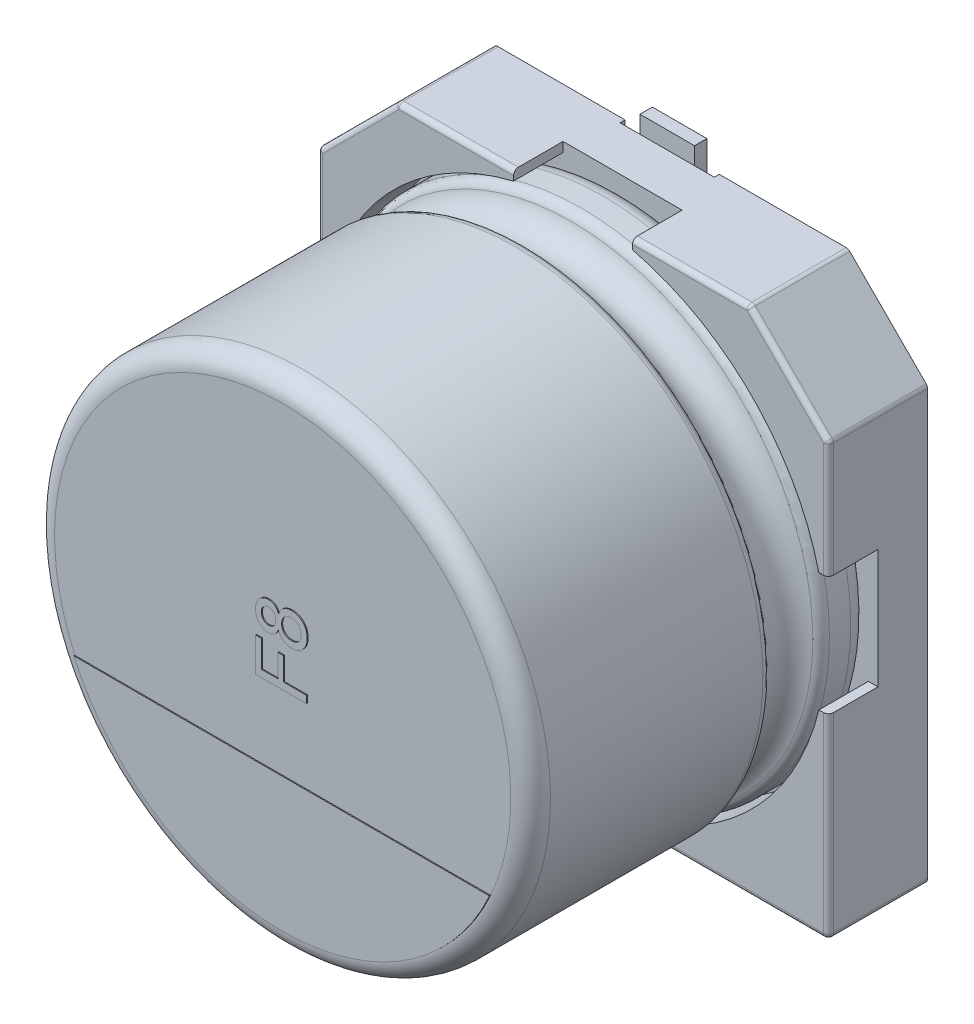
from build123d import *

# Parameters (mm, degrees)
BOSS_EXTRUDE1_DEPTH  = 1
BOSS_EXTRUDE2_DEPTH  = 1
SKETCH7_R            = 0.35
SPACER_PAD_DEPTH     = 0.15
SKETCH9_W            = 1.9
SKETCH9_H            = 3.05
CUT_EXTRUDE1_DEPTH   = 0.1
FILLET1_R            = 0.1
FILLET2_R            = 0.1
CATHODE_MARKER_DEPTH = 0.02
TEXT_2_DEPTH         = 0.02
SKETCH19_W           = 1.1
SKETCH19_H           = 3.2
BOSS_EXTRUDE6_DEPTH  = 0.25


with BuildPart() as part:
    # Sketch2 → Boss-Extrude1 (new body)
    with BuildSketch(Plane.XY):
        Polygon((-5.15, 3.55), (-3.55, 5.15), (3.55, 5.15), (5.15, 3.55), (5.15, -5.15), (-5.15, -5.15), align=None)
    extrude(amount=BOSS_EXTRUDE1_DEPTH)

    # Sketch4 → Boss-Extrude2 (add)
    with BuildSketch(Plane.XY.offset(1)):
        with BuildLine():
            Line((-5.15, 3.55), (-3.55, 5.15))
            Line((-3.55, 5.15), (-1.2, 5.15))
            Line((-1.2, 5.15), (-1.2, 4.956813493))
            ThreePointArc((-1.2, 4.956813493), (-3.606244584, 3.606244584), (-4.956813493, 1.2))
            Line((-4.956813493, 1.2), (-5.15, 1.2))
            Line((-5.15, 1.2), (-5.15, 3.55))
        make_face()
        with BuildLine():
            Line((3.55, 5.15), (5.15, 3.55))
            Line((5.15, 3.55), (5.15, 1.2))
            Line((5.15, 1.2), (4.956813493, 1.2))
            ThreePointArc((4.956813493, 1.2), (3.606244584, 3.606244584), (1.2, 4.956813493))
            Line((1.2, 4.956813493), (1.2, 5.15))
            Line((1.2, 5.15), (3.55, 5.15))
        make_face()
        with BuildLine():
            Line((5.15, -1.2), (5.15, -5.15))
            Line((5.15, -5.15), (1.2, -5.15))
            Line((1.2, -5.15), (1.2, -4.956813493))
            ThreePointArc((1.2, -4.956813493), (3.606244584, -3.606244584), (4.956813493, -1.2))
            Line((4.956813493, -1.2), (5.15, -1.2))
        make_face()
        with BuildLine():
            Line((-5.15, -1.2), (-5.15, -5.15))
            Line((-5.15, -5.15), (-1.2, -5.15))
            Line((-1.2, -5.15), (-1.2, -4.956813493))
            ThreePointArc((-1.2, -4.956813493), (-3.606244584, -3.606244584), (-4.956813493, -1.2))
            Line((-4.956813493, -1.2), (-5.15, -1.2))
        make_face()
    extrude(amount=BOSS_EXTRUDE2_DEPTH)

    # Sketch7 → Spacer Pad (add)
    with BuildSketch(Plane(origin=(0, 0, 0), x_dir=(1, 0, 0), z_dir=(0, 0, -1))):
        with Locations((-3.581612435, 3.54735769)):
            Circle(SKETCH7_R)
        with Locations((3.581612435, 3.54735769)):
            Circle(SKETCH7_R)
        with Locations((-3.581612435, -3.54735769)):
            Circle(SKETCH7_R)
        with Locations((3.581612435, -3.54735769)):
            Circle(SKETCH7_R)
    extrude(amount=SPACER_PAD_DEPTH)

    # Sketch9 → Cut-Extrude1 (cut)
    with BuildSketch(Plane(origin=(0, 0, 0), x_dir=(1, 0, 0), z_dir=(0, 0, -1))):
        with Locations((0, 3.625)):
            Rectangle(SKETCH9_W, SKETCH9_H)
        with Locations((0, -3.625)):
            Rectangle(SKETCH9_W, SKETCH9_H)
    extrude(amount=-CUT_EXTRUDE1_DEPTH, mode=Mode.SUBTRACT)

    # Fillet1
    fillet1_edges = [part.edges().sort_by_distance(p)[0] for p in [
        (5.15, -5.15, 1),
        (-5.15, -5.15, 1),
        (-5.15, 3.55, 1),
        (-3.55, 5.15, 1),
        (3.55, 5.15, 1),
        (5.15, 3.55, 1),
    ]]
    fillet(fillet1_edges, radius=FILLET1_R)

    # Sketch10 → Revolve1 (revolve)
    with BuildSketch(Plane(origin=(0, 0, 0), x_dir=(0, 0, -1), z_dir=(1, 0, 0))):
        with BuildLine():
            Line((-7.853626625, 0), (-1, 0))
            Line((-1, 0), (-1, 4.6))
            ThreePointArc((-1, 4.6), (-1.117157288, 4.882842712), (-1.4, 5))
            Line((-1.4, 5), (-1.829179607, 5))
            ThreePointArc((-1.829179607, 5), (-1.948702468, 4.960356745), (-2.020842576, 4.857142857))
            ThreePointArc((-2.020842576, 4.857142857), (-2.5, 4.5), (-2.979157424, 4.857142857))
            ThreePointArc((-2.979157424, 4.857142857), (-3.051297532, 4.960356745), (-3.170820393, 5))
            Line((-3.170820393, 5), (-7.453626625, 5))
            ThreePointArc((-7.453626625, 5), (-7.736469337, 4.882842712), (-7.853626625, 4.6))
            Line((-7.853626625, 4.6), (-7.853626625, 0))
        make_face()
    revolve(axis=Axis((0, 0, -18.9630778), (0, 0, 1)))

    # Fillet2
    fillet2_edges = [part.edges().sort_by_distance(p)[0] for p in [
        (3.125, -5.15, 2),
        (5.120710678, -5.120710678, 2),
        (5.15, 2.354289322, 2),
        (5.142387953, 3.546846987, 2),
        (2.354289322, 5.15, 2),
        (3.546846987, 5.142387953, 2),
        (-2.354289322, 5.15, 2),
        (-3.546846987, 5.142387953, 2),
        (-4.35, 4.35, 2),
        (-5.142387953, 3.546846987, 2),
        (-5.15, -3.125, 2),
        (-5.120710678, -5.120710678, 2),
        (5.15, -3.125, 2),
        (4.35, 4.35, 2),
        (-5.15, 2.354289322, 2),
        (-3.125, -5.15, 2),
    ]]
    fillet(fillet2_edges, radius=FILLET2_R)

    # Sketch13 → Cathode marker (add)
    with BuildSketch(Plane.XY.offset(7.853626625)):
        with BuildLine():
            Line((-4.192254052, -1.893411197), (4.192254052, -1.893411197))
            ThreePointArc((4.192254052, -1.893411197), (0, -4.6), (-4.192254052, -1.893411197))
        make_face()
    extrude(amount=CATHODE_MARKER_DEPTH)

    # Sketch15 → Text 2 (add)
    with BuildSketch(Plane.XY.offset(7.853626625)):
        Polygon((0.5, -0.381462215), (-0.527327474, -0.381462215), (-0.527327474, 0.303422768), (-0.408789689, 0.303422768), (-0.408789689, -0.236582699), (-0.079518062, -0.236582699), (-0.079518062, 0.224397578), (0.039019723, 0.224397578), (0.039019723, -0.236582699), (0.5, -0.236582699), align=None)
        with BuildLine():
            add(Edge.make_bspline(
                [(-0.06346607, 0.630224857), (-0.068354899, 0.617728032), (-0.077728405, 0.593767474), (-0.096487429, 0.561450859), (-0.118067216, 0.534100009), (-0.142988147, 0.512050759), (-0.17073504, 0.495245221), (-0.200954123, 0.483144569), (-0.233813748, 0.476057005), (-0.256535333, 0.4751242), (-0.268231863, 0.474644014)],
                knots=[0, 0, 0, 0, 1.16287356, 2.229614231, 3.228817875, 4.173350329, 5.100165549, 6.029633206, 6.985702163, 8, 8, 8, 8], degree=3))
            add(Edge.make_bspline(
                [(-0.268231863, 0.474644014), (-0.277232165, 0.474869153), (-0.29490004, 0.475311109), (-0.320818877, 0.479156569), (-0.345615231, 0.485235553), (-0.369240102, 0.494102611), (-0.392048008, 0.504848512), (-0.413437716, 0.518699867), (-0.434030491, 0.534521), (-0.453013793, 0.553071964), (-0.470402473, 0.573510242), (-0.485876208, 0.595649315), (-0.498530082, 0.619657127), (-0.509109754, 0.645133792), (-0.517392528, 0.672205173), (-0.523033555, 0.700966658), (-0.526621668, 0.73131685), (-0.527088541, 0.752113523), (-0.527327474, 0.762756687)],
                knots=[0, 0, 0, 0, 0.994120188, 1.951489002, 2.889176796, 3.810168517, 4.735797202, 5.669554404, 6.620327554, 7.601413351, 8.596342518, 9.582569514, 10.579662357, 11.589070759, 12.627413041, 13.702304436, 14.824102725, 16, 16, 16, 16], degree=3))
            add(Edge.make_bspline(
                [(-0.527327474, 0.762756687), (-0.527086115, 0.77346767), (-0.526615976, 0.794331457), (-0.523076073, 0.824842893), (-0.517142977, 0.853785883), (-0.508725404, 0.881143376), (-0.497963042, 0.906958535), (-0.484734644, 0.931061617), (-0.469258577, 0.953701153), (-0.451349578, 0.974296996), (-0.431908305, 0.993041001), (-0.411072648, 1.00926575), (-0.389310753, 1.023268876), (-0.366468595, 1.034605267), (-0.342477715, 1.043273729), (-0.317627507, 1.049701953), (-0.291602408, 1.053478006), (-0.27393779, 1.053931208), (-0.264939147, 1.054162076)],
                knots=[0, 0, 0, 0, 1.17123639, 2.281436327, 3.354066579, 4.398218719, 5.40700272, 6.407523026, 7.400164541, 8.400262835, 9.387217769, 10.349220476, 11.2836808, 12.213067748, 13.131580738, 14.068687581, 15.016158091, 16, 16, 16, 16], degree=3))
            add(Edge.make_bspline(
                [(-0.264939147, 1.054162076), (-0.253645841, 1.053785591), (-0.231501792, 1.053047375), (-0.199579354, 1.045527123), (-0.169784312, 1.033800759), (-0.142655025, 1.016872367), (-0.117991462, 0.995331285), (-0.096234769, 0.968911116), (-0.077820532, 0.937308758), (-0.068384192, 0.914014612), (-0.06346607, 0.901873949)],
                knots=[0, 0, 0, 0, 0.998585552, 1.958038425, 2.887636572, 3.823348935, 4.774921793, 5.776035998, 6.840893412, 8, 8, 8, 8], degree=3))
            add(Edge.make_bspline(
                [(-0.06346607, 0.901873949), (-0.060862641, 0.909543442), (-0.055761048, 0.924572322), (-0.04584198, 0.945818674), (-0.035146871, 0.965821476), (-0.023569407, 0.984693522), (-0.010248607, 1.001738218), (0.00402795, 1.017524151), (0.019461358, 1.031985221), (0.036183215, 1.044922897), (0.053841314, 1.05647651), (0.072483356, 1.066356607), (0.091886088, 1.074813533), (0.112087026, 1.081859998), (0.133157783, 1.087220063), (0.15505702, 1.090842682), (0.177743724, 1.093179531), (0.193154177, 1.093507908), (0.200980204, 1.093674671)],
                knots=[0, 0, 0, 0, 1.104224237, 2.163800432, 3.193825792, 4.198757877, 5.179651902, 6.140335883, 7.100472673, 8.060837497, 9.021293519, 9.975895278, 10.935667101, 11.906463585, 12.891589942, 13.897828549, 14.932435592, 16, 16, 16, 16], degree=3))
            add(Edge.make_bspline(
                [(0.200980204, 1.093674671), (0.211766209, 1.093412666), (0.233015459, 1.092896496), (0.26420908, 1.088369563), (0.294166278, 1.081500633), (0.322741766, 1.071575782), (0.349926401, 1.058632915), (0.375922546, 1.043019303), (0.400458109, 1.024360181), (0.423424312, 1.003168612), (0.444607119, 0.979931258), (0.463042568, 0.954460148), (0.478495248, 0.927073343), (0.491395014, 0.89804463), (0.50090607, 0.867031977), (0.508283383, 0.834461777), (0.512303421, 0.799968902), (0.512877843, 0.77641717), (0.513170865, 0.764403045)],
                knots=[0, 0, 0, 0, 1.017684271, 2.004915574, 2.969350057, 3.91550174, 4.854021697, 5.806886265, 6.773058391, 7.758397691, 8.753308551, 9.736453685, 10.719577492, 11.717014045, 12.728747378, 13.776699948, 14.865858151, 16, 16, 16, 16], degree=3))
            add(Edge.make_bspline(
                [(0.513170865, 0.764403045), (0.512880184, 0.752388096), (0.51231035, 0.728834748), (0.508257359, 0.694353476), (0.500993774, 0.661721267), (0.49106014, 0.630864182), (0.478602189, 0.601614834), (0.462789127, 0.574405171), (0.444350128, 0.548860334), (0.423269613, 0.525384311), (0.40009517, 0.504226358), (0.375232143, 0.485808918), (0.349063166, 0.470109933), (0.321440718, 0.45719001), (0.292364548, 0.447342081), (0.261943817, 0.440430689), (0.230201772, 0.435891796), (0.208542071, 0.435388449), (0.197481693, 0.435131419)],
                knots=[0, 0, 0, 0, 1.127066097, 2.209429196, 3.250843736, 4.258219581, 5.246860502, 6.227045772, 7.204057202, 8.19754525, 9.181483529, 10.142920909, 11.095356922, 12.039670968, 12.998174893, 13.969127444, 14.962948905, 16, 16, 16, 16], degree=3))
            add(Edge.make_bspline(
                [(0.197481693, 0.435131419), (0.189246409, 0.435310056), (0.173087356, 0.435660572), (0.149386601, 0.437802244), (0.126796614, 0.442069091), (0.105187415, 0.447569664), (0.084493636, 0.454537156), (0.064863806, 0.463216556), (0.046256659, 0.473537299), (0.028790272, 0.485492066), (0.012456006, 0.498840473), (-0.002360853, 0.513783706), (-0.01598593, 0.529886288), (-0.028435302, 0.547220798), (-0.039376701, 0.566040821), (-0.048734162, 0.586294961), (-0.057112711, 0.607690465), (-0.061327074, 0.622638166), (-0.06346607, 0.630224857)],
                knots=[0, 0, 0, 0, 1.117192714, 2.192125398, 3.223277125, 4.232061974, 5.214850236, 6.181337876, 7.139322725, 8.096810377, 9.04872078, 9.996164021, 10.946891304, 11.907403346, 12.887280159, 13.894604929, 14.93140868, 16, 16, 16, 16], degree=3))
        make_face()
        with BuildLine():
            add(Edge.make_bspline(
                [(-0.267614479, 0.606352664), (-0.257129573, 0.606743584), (-0.236868083, 0.607499015), (-0.208087697, 0.615714054), (-0.182236441, 0.628560707), (-0.163484759, 0.643618999), (-0.150719359, 0.658060881), (-0.142164759, 0.670101748), (-0.135012669, 0.683333668), (-0.128993841, 0.697571346), (-0.124418959, 0.712960773), (-0.121517723, 0.729542592), (-0.119286059, 0.747193981), (-0.119117208, 0.759387586), (-0.119030657, 0.765637813)],
                knots=[0, 0, 0, 0, 1.528611259, 2.9539551, 4.33488699, 5.725248612, 6.435430486, 7.147520411, 7.878829355, 8.629199951, 9.403175758, 10.219188982, 11.087187622, 12, 12, 12, 12], degree=3))
            add(Edge.make_bspline(
                [(-0.119030657, 0.765637813), (-0.119118527, 0.771750551), (-0.119289868, 0.783670055), (-0.121500048, 0.800917287), (-0.124496051, 0.817197129), (-0.1288828, 0.832380294), (-0.135118016, 0.846282108), (-0.14191772, 0.859386968), (-0.150526036, 0.871162403), (-0.163313755, 0.885282045), (-0.181426583, 0.900214979), (-0.205975026, 0.913234897), (-0.232964043, 0.92120307), (-0.251781791, 0.922029323), (-0.261440636, 0.922453425)],
                knots=[0, 0, 0, 0, 0.922426077, 1.79868034, 2.621444266, 3.421127716, 4.177365866, 4.918918382, 5.646226505, 6.372279565, 7.792748194, 9.164334355, 10.544498862, 12, 12, 12, 12], degree=3))
            add(Edge.make_bspline(
                [(-0.261440636, 0.922453425), (-0.271437729, 0.921944865), (-0.290999452, 0.920949743), (-0.319104756, 0.912959472), (-0.344515741, 0.899362045), (-0.363325638, 0.88420153), (-0.376567635, 0.869715951), (-0.385082022, 0.857520324), (-0.392715367, 0.844570951), (-0.398298846, 0.830316684), (-0.4031971, 0.815320156), (-0.406317846, 0.79921269), (-0.408535579, 0.782163313), (-0.408703203, 0.770447701), (-0.408789689, 0.764403045)],
                knots=[0, 0, 0, 0, 1.480375879, 2.896712224, 4.288636353, 5.727462819, 6.454578368, 7.191019914, 7.928864207, 8.676661479, 9.454949272, 10.264623217, 11.104634354, 12, 12, 12, 12], degree=3))
            add(Edge.make_bspline(
                [(-0.408789689, 0.764403045), (-0.408707781, 0.758357199), (-0.408548105, 0.746571118), (-0.406239515, 0.729417769), (-0.403494721, 0.713112148), (-0.398497735, 0.698074812), (-0.392892961, 0.683878498), (-0.385509663, 0.670876063), (-0.377188483, 0.658686443), (-0.364322549, 0.644327219), (-0.34623511, 0.629283184), (-0.321930657, 0.616031701), (-0.295432267, 0.607841427), (-0.277001926, 0.606855065), (-0.267614479, 0.606352664)],
                knots=[0, 0, 0, 0, 0.91490328, 1.783559258, 2.619081745, 3.414352434, 4.178467273, 4.927311119, 5.673844605, 6.409891731, 7.841381988, 9.212979491, 10.580438247, 12, 12, 12, 12], degree=3))
        make_face(mode=Mode.SUBTRACT)
        with BuildLine():
            add(Edge.make_bspline(
                [(0.195012156, 0.566840069), (0.203533443, 0.56705796), (0.220461909, 0.567490824), (0.245646107, 0.571589886), (0.270289152, 0.578228299), (0.29446295, 0.587073856), (0.317223577, 0.599279301), (0.337556487, 0.615574955), (0.354705064, 0.635928841), (0.368908515, 0.659374721), (0.380259094, 0.684798285), (0.388514475, 0.711251777), (0.393687613, 0.738202876), (0.394317888, 0.756354599), (0.39463308, 0.765432019)],
                knots=[0, 0, 0, 0, 0.965767917, 1.918603253, 2.884747077, 3.857165743, 4.83191542, 5.800217878, 6.793357779, 7.834047487, 8.899591186, 9.942836448, 10.971241714, 12, 12, 12, 12], degree=3))
            add(Edge.make_bspline(
                [(0.39463308, 0.765432019), (0.394506238, 0.772918557), (0.39425982, 0.787462767), (0.391444872, 0.808663977), (0.387171918, 0.82863916), (0.38131905, 0.847485134), (0.37329041, 0.864905696), (0.363961235, 0.88128906), (0.35239897, 0.89617309), (0.339512355, 0.909881545), (0.325396783, 0.922286139), (0.309987757, 0.932728591), (0.293890018, 0.941913815), (0.276740007, 0.949400273), (0.258518154, 0.954817388), (0.23954893, 0.958996534), (0.219637866, 0.961517903), (0.20606374, 0.961814483), (0.199128051, 0.961966021)],
                knots=[0, 0, 0, 0, 1.149503616, 2.233157837, 3.279104951, 4.285657945, 5.257288299, 6.220710859, 7.175564347, 8.14479123, 9.108444329, 10.055589725, 10.999387165, 11.952843816, 12.922929765, 13.915146356, 14.934745671, 16, 16, 16, 16], degree=3))
            add(Edge.make_bspline(
                [(0.199128051, 0.961966021), (0.192056214, 0.961809671), (0.178210684, 0.961503563), (0.15786274, 0.959046074), (0.138559314, 0.95463328), (0.120012744, 0.948953773), (0.102531334, 0.941273588), (0.085868825, 0.931965865), (0.070322849, 0.920792043), (0.05566719, 0.908314754), (0.042426027, 0.894282366), (0.030949228, 0.878853772), (0.021138856, 0.862258468), (0.013340834, 0.844392154), (0.007158914, 0.825364854), (0.002647348, 0.805186415), (-0.000105556, 0.783755537), (-0.000361274, 0.769076231), (-0.000492872, 0.761521918)],
                knots=[0, 0, 0, 0, 1.065650327, 2.086373591, 3.082132111, 4.046704089, 5.005106566, 5.954038819, 6.917890284, 7.885615098, 8.851017768, 9.818687358, 10.777925871, 11.749948522, 12.750365274, 13.788736846, 14.862032431, 16, 16, 16, 16], degree=3))
            add(Edge.make_bspline(
                [(-0.000492872, 0.761521918), (-0.000359965, 0.75417275), (-9.9427e-05, 0.739766091), (0.002669058, 0.718836081), (0.006928426, 0.699025963), (0.013134854, 0.68049079), (0.020971302, 0.663100134), (0.030472426, 0.64688593), (0.041878437, 0.631961115), (0.055055679, 0.618499167), (0.069403746, 0.606379785), (0.084799219, 0.595815852), (0.10098144, 0.586670171), (0.11825962, 0.57957126), (0.136157909, 0.573630612), (0.155039621, 0.56990608), (0.174700988, 0.567261621), (0.188142811, 0.56698264), (0.195012156, 0.566840069)],
                knots=[0, 0, 0, 0, 1.134968506, 2.224891707, 3.256179866, 4.261763128, 5.239014399, 6.198865146, 7.159242496, 8.133730563, 9.104116964, 10.05674163, 11.0152453, 11.970049417, 12.938813484, 13.924193867, 14.939174528, 16, 16, 16, 16], degree=3))
        make_face(mode=Mode.SUBTRACT)
    extrude(amount=TEXT_2_DEPTH)

    # Sketch19 → Boss-Extrude6 (add)
    with BuildSketch(Plane(origin=(0, 0, 0.1), x_dir=(1, 0, 0), z_dir=(0, 0, -1))):
        with Locations((0, 3.9)):
            Rectangle(SKETCH19_W, SKETCH19_H)
        with Locations((0, -3.9)):
            Rectangle(SKETCH19_W, SKETCH19_H)
    extrude(amount=BOSS_EXTRUDE6_DEPTH)


solid = part.part
